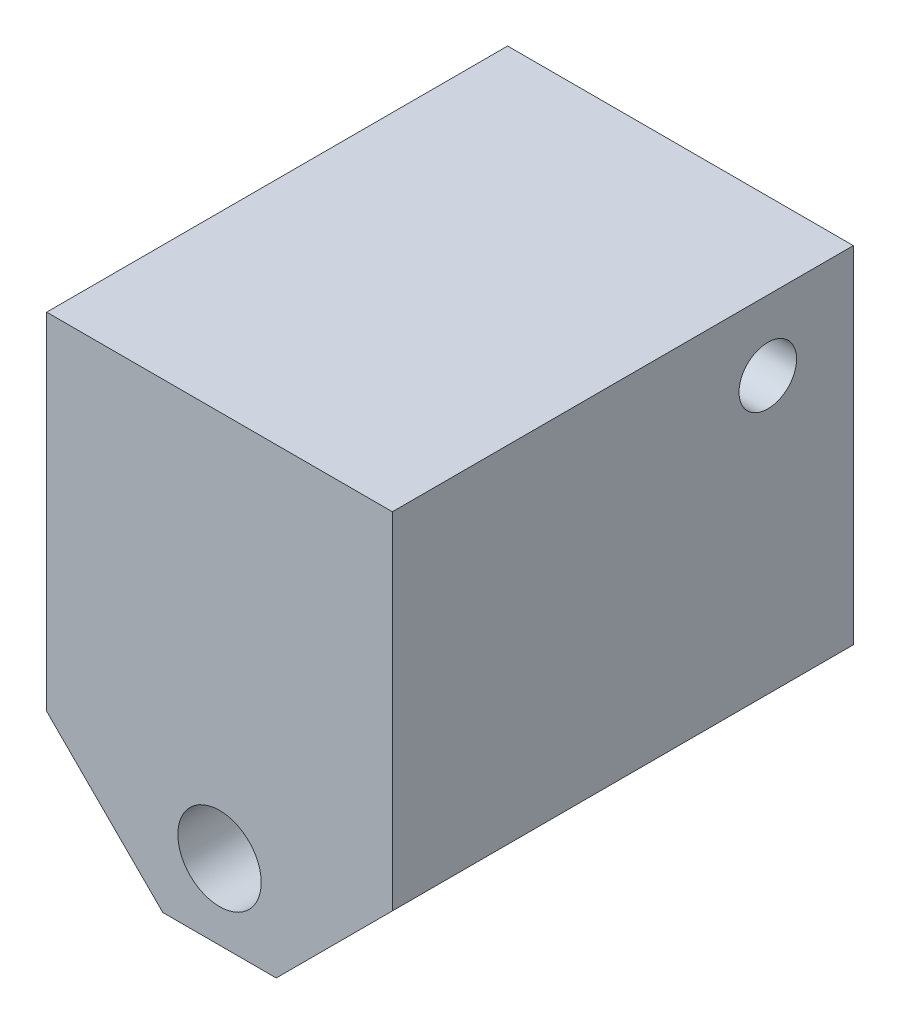
from build123d import *

# Parameters (mm, degrees)
SKETCH1_R             = 3.617136877
BOSS_EXTRUDE1_DEPTH   = 40
F_5_0MM_DOWEL_HOLE1_D = 5


with BuildPart() as part:
    # Sketch1 → Boss-Extrude1 (new body)
    with BuildSketch(Plane.XY):
        Polygon((-15, -15), (-4.922326912, -25.077673088), (4.922326912, -25.077673088), (15, -15), (15, 15), (-15, 15), align=None)
        with Locations((0, -18.555652187)):
            Circle(SKETCH1_R, mode=Mode.SUBTRACT)
    extrude(amount=BOSS_EXTRUDE1_DEPTH)

    # Ø5.0mm Dowel Hole1 (through all)
    with Locations(Plane(origin=(15, 8.941860577, 7.42320161), x_dir=(0, 1, 0), z_dir=(1, 0, 0))):
        with Locations((0, 0)):
            Hole(F_5_0MM_DOWEL_HOLE1_D / 2)


solid = part.part
